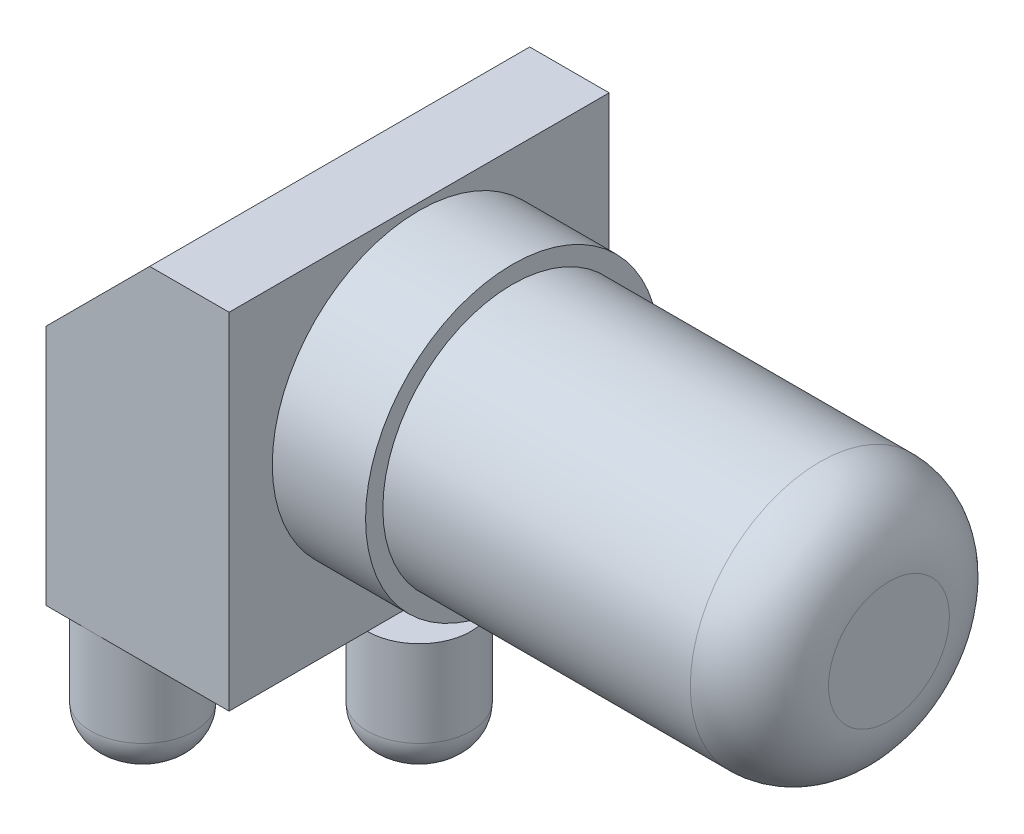
from build123d import *

# Parameters (mm, degrees)
SKETCH1_R             = 1.905
BOSS_EXTRUDE1_DEPTH   = 4.445
BOSS_EXTRUDE1_2_DEPTH = 4.445
BOSS_EXTRUDE1_3_DEPTH = 4.445
SKETCH1_R_2           = 1.27
BOSS_EXTRUDE1_4_DEPTH = 4.445
SKETCH2_W             = 6.731
SKETCH2_H             = 13.97
BOSS_EXTRUDE2_DEPTH   = 12.7
CHAMFER1_SIZE         = 3.81
SKETCH3_R             = 5.3975
BOSS_EXTRUDE3_DEPTH   = 3.429
SKETCH4_R             = 4.7625
BOSS_EXTRUDE4_DEPTH   = 13.843
FILLET1_R             = 2.54
FILLET2_R             = 1.27


with BuildPart() as part:
    # Sketch1 → Boss-Extrude1 (new body)
    with BuildSketch(Plane(origin=(0, 0, 0), x_dir=(1, 0, 0), z_dir=(0, 1, 0))):
        with Locations((0.635, 5.08)):
            Circle(SKETCH1_R)
    extrude(amount=-BOSS_EXTRUDE1_DEPTH)



with BuildPart() as body_2:
    # Sketch1 → Boss-Extrude1 2 (new body)
    with BuildSketch(Plane(origin=(0, 0, 0), x_dir=(1, 0, 0), z_dir=(0, 1, 0))):
        with Locations((0.635, -5.08)):
            Circle(SKETCH1_R)
    extrude(amount=-BOSS_EXTRUDE1_2_DEPTH)


with BuildPart() as body_3:
    # Sketch1 → Boss-Extrude1 3 (new body)
    with BuildSketch(Plane(origin=(0, 0, 0), x_dir=(1, 0, 0), z_dir=(0, 1, 0))):
        with Locations((5.715, 0)):
            Circle(SKETCH1_R)
    extrude(amount=-BOSS_EXTRUDE1_3_DEPTH)


with BuildPart() as body_4:
    # Sketch1 → Boss-Extrude1 4 (new body)
    with BuildSketch(Plane(origin=(0, 0, 0), x_dir=(1, 0, 0), z_dir=(0, 1, 0))):
        Circle(SKETCH1_R_2)
    extrude(amount=-BOSS_EXTRUDE1_4_DEPTH)


with BuildPart() as part_1:
    add(part.part)

    add(body_2.part)  # Boss-Extrude2 merges body 2

    add(body_3.part)  # Boss-Extrude2 merges body 3

    add(body_4.part)  # Boss-Extrude2 merges body 4
    # Sketch2 → Boss-Extrude2 (add)
    with BuildSketch(Plane(origin=(0, 0, 0), x_dir=(-1, 0, 0), z_dir=(0, 1, 0))):
        with Locations((-2.3495, 0)):
            Rectangle(SKETCH2_W, SKETCH2_H)
    extrude(amount=BOSS_EXTRUDE2_DEPTH)

    # Chamfer1
    chamfer1_edges = [part_1.edges().sort_by_distance(p)[0] for p in [
        (-1.016, 12.7, 0),
    ]]
    chamfer(chamfer1_edges, length=CHAMFER1_SIZE)

    # Sketch3 → Boss-Extrude3 (add)
    with BuildSketch(Plane(origin=(5.715, 0, 0), x_dir=(0, 0, -1), z_dir=(1, 0, 0))):
        with Locations((0, 7.0485)):
            Circle(SKETCH3_R)
    extrude(amount=BOSS_EXTRUDE3_DEPTH)

    # Sketch4 → Boss-Extrude4 (add)
    with BuildSketch(Plane(origin=(9.144, 0, 0), x_dir=(0, 0, -1), z_dir=(1, 0, 0))):
        with Locations((0, 7.0485)):
            Circle(SKETCH4_R)
    extrude(amount=BOSS_EXTRUDE4_DEPTH)

    # Fillet1
    fillet1_edges = [part_1.edges().sort_by_distance(p)[0] for p in [
        (22.987, 7.0485, 4.7625),
    ]]
    fillet(fillet1_edges, radius=FILLET1_R)

    # Fillet2
    fillet2_edges = [part_1.edges().sort_by_distance(p)[0] for p in [
        (-1.27, -4.445, 5.08),
        (3.81, -4.445, 0),
        (-1.27, -4.445, 0),
        (-1.27, -4.445, -5.08),
    ]]
    fillet(fillet2_edges, radius=FILLET2_R)


solid = part_1.part
